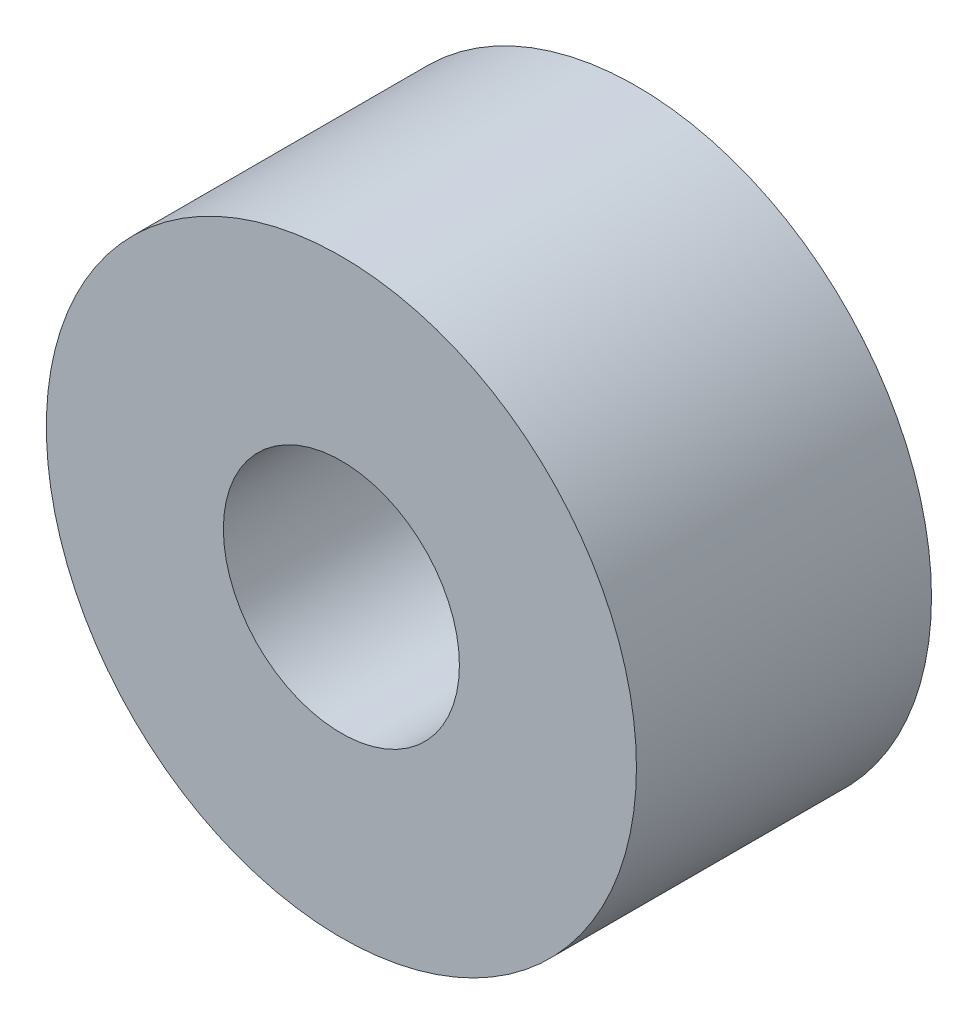
from build123d import *

# Parameters (mm, degrees)
SKETCH1_R           = 4
SKETCH1_R_2         = 1.6
EXTRUDE1_DEPTH      = 2
EXTRUDE1_DEPTH_BACK = 2


with BuildPart() as part:
    # Sketch1 → Extrude1 (new body, two sides)
    with BuildSketch(Plane.XY) as extrude1_sk:
        Circle(SKETCH1_R)
        Circle(SKETCH1_R_2, mode=Mode.SUBTRACT)
    extrude(amount=EXTRUDE1_DEPTH)
    extrude(extrude1_sk.sketch, amount=-EXTRUDE1_DEPTH_BACK)


solid = part.part
